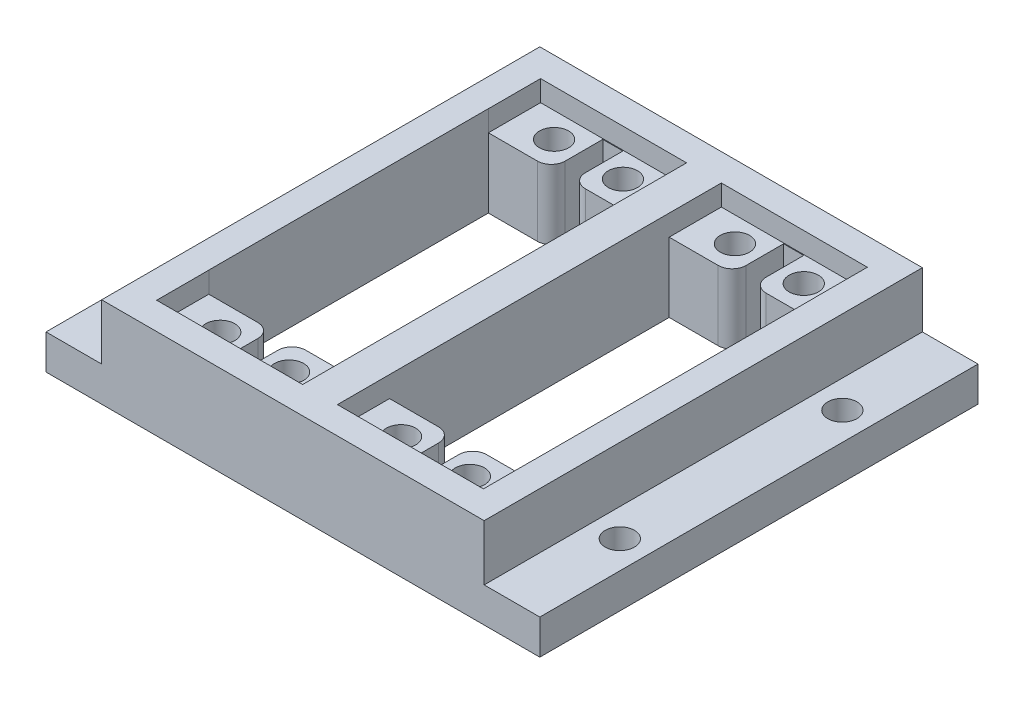
from build123d import *

# Parameters (mm, degrees)
SKETCH2_W           = 55
SKETCH2_H           = 63
SKETCH2_R           = 2.1
BOSS_EXTRUDE1_DEPTH = 13
SKETCH3_W           = 20.991665644
SKETCH3_H           = 7.5
CUT_EXTRUDE1_DEPTH  = 3
SKETCH2_3_W         = 8
SKETCH2_3_H         = 63
SKETCH2_3_R         = 2.1
BOSS_EXTRUDE2_DEPTH = 5


with BuildPart() as part:
    # Sketch2 → Boss-Extrude1 (new body)
    with BuildSketch(Plane(origin=(0, 0, 0), x_dir=(1, 0, 0), z_dir=(0, 1, 0))):
        Rectangle(SKETCH2_W, SKETCH2_H)
        with Locations((-17.95, -24)):
            Circle(SKETCH2_R, mode=Mode.SUBTRACT)
        with Locations((-8.05, -24)):
            Circle(SKETCH2_R, mode=Mode.SUBTRACT)
        with Locations((8.05, -24)):
            Circle(SKETCH2_R, mode=Mode.SUBTRACT)
        with Locations((17.95, -24)):
            Circle(SKETCH2_R, mode=Mode.SUBTRACT)
        with BuildLine():
            Line((14.45, -27.5), (11.55, -27.5))
            Line((11.55, -27.5), (11.55, -22.1))
            ThreePointArc((11.55, -22.1), (10.964213562, -20.685786438), (9.55, -20.1))
            Line((9.55, -20.1), (2.5, -20.1))
            Line((2.5, -20.1), (2.5, 20.1))
            Line((2.5, 20.1), (9.55, 20.1))
            ThreePointArc((9.55, 20.1), (10.964213562, 20.685786438), (11.55, 22.1))
            Line((11.55, 22.1), (11.55, 27.5))
            Line((11.55, 27.5), (14.45, 27.5))
            Line((14.45, 27.5), (14.45, 22.1))
            ThreePointArc((14.45, 22.1), (15.035786438, 20.685786438), (16.45, 20.1))
            Line((16.45, 20.1), (23.5, 20.1))
            Line((23.5, 20.1), (23.5, -20.1))
            Line((23.5, -20.1), (16.45, -20.1))
            ThreePointArc((16.45, -20.1), (15.035786438, -20.685786438), (14.45, -22.1))
            Line((14.45, -22.1), (14.45, -27.5))
        make_face(mode=Mode.SUBTRACT)
        with BuildLine():
            Line((-23.5, 20.1), (-16.45, 20.1))
            ThreePointArc((-16.45, 20.1), (-15.035786438, 20.685786438), (-14.45, 22.1))
            Line((-14.45, 22.1), (-14.45, 27.5))
            Line((-14.45, 27.5), (-11.55, 27.5))
            Line((-11.55, 27.5), (-11.55, 22.1))
            ThreePointArc((-11.55, 22.1), (-10.964213562, 20.685786438), (-9.55, 20.1))
            Line((-9.55, 20.1), (-2.5, 20.1))
            Line((-2.5, 20.1), (-2.5, -20.1))
            Line((-2.5, -20.1), (-9.55, -20.1))
            ThreePointArc((-9.55, -20.1), (-10.964213562, -20.685786438), (-11.55, -22.1))
            Line((-11.55, -22.1), (-11.55, -27.5))
            Line((-11.55, -27.5), (-14.45, -27.5))
            Line((-14.45, -27.5), (-14.45, -22.1))
            ThreePointArc((-14.45, -22.1), (-15.035786438, -20.685786438), (-16.45, -20.1))
            Line((-16.45, -20.1), (-23.5, -20.1))
            Line((-23.5, -20.1), (-23.5, 20.1))
        make_face(mode=Mode.SUBTRACT)
        with Locations((-17.95, 24)):
            Circle(SKETCH2_R, mode=Mode.SUBTRACT)
        with Locations((-8.05, 24)):
            Circle(SKETCH2_R, mode=Mode.SUBTRACT)
        with Locations((8.05, 24)):
            Circle(SKETCH2_R, mode=Mode.SUBTRACT)
        with Locations((17.95, 24)):
            Circle(SKETCH2_R, mode=Mode.SUBTRACT)
    extrude(amount=BOSS_EXTRUDE1_DEPTH)

    # Sketch3 → Cut-Extrude1 (cut)
    with BuildSketch(Plane(origin=(0, 13, 0), x_dir=(1, 0, 0), z_dir=(0, 1, 0))):
        with Locations((12.995832822, 23.85)):
            Rectangle(SKETCH3_W, SKETCH3_H)
        with Locations((12.995832822, -23.85)):
            Rectangle(SKETCH3_W, SKETCH3_H)
        with Locations((-12.995832822, -23.85)):
            Rectangle(SKETCH3_W, SKETCH3_H)
        with Locations((-12.995832822, 23.85)):
            Rectangle(SKETCH3_W, SKETCH3_H)
    extrude(amount=-CUT_EXTRUDE1_DEPTH, mode=Mode.SUBTRACT)

    # Sketch2_3 → Boss-Extrude2 (add)
    # profile 1 of 2: a face of its own
    with BuildSketch(Plane(origin=(0, 0, 0), x_dir=(1, 0, 0), z_dir=(0, 1, 0))):
        with Locations((-31.5, 0)):
            Rectangle(SKETCH2_3_W, SKETCH2_3_H)
        with Locations((-31.5, -16)):
            Circle(SKETCH2_3_R, mode=Mode.SUBTRACT)
        with Locations((-31.5, 16)):
            Circle(SKETCH2_3_R, mode=Mode.SUBTRACT)
    # profile 2 of 2: a face of its own
    with BuildSketch(Plane(origin=(0, 0, 0), x_dir=(1, 0, 0), z_dir=(0, 1, 0))):
        with Locations((31.5, 0)):
            Rectangle(SKETCH2_3_W, SKETCH2_3_H)
        with Locations((31.5, -16)):
            Circle(SKETCH2_3_R, mode=Mode.SUBTRACT)
        with Locations((31.5, 16)):
            Circle(SKETCH2_3_R, mode=Mode.SUBTRACT)
    extrude(amount=BOSS_EXTRUDE2_DEPTH)


solid = part.part
